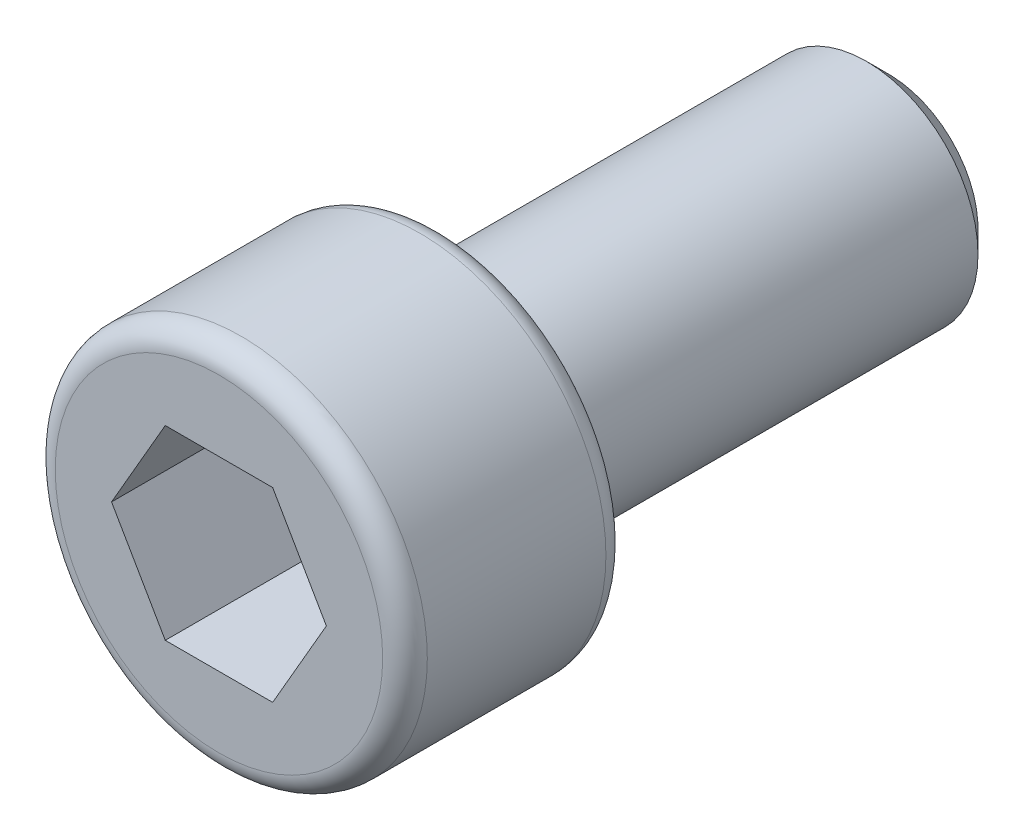
from build123d import *

# Parameters (mm, degrees)
SKETCH_1_R          = 2.5
EXTRUDE_1_DEPTH     = 3
SKETCH_2_R          = 1.5
EXTRUDE_2_DEPTH     = 6
CUT_EXTRUDE_1_DEPTH = 2
CHAMFER_1_SIZE      = 0.3
FILLET_1_R          = 0.3


with BuildPart() as part:
    # 草图1 → 凸台-拉伸1 (new body)
    with BuildSketch(Plane.XY):
        Circle(SKETCH_1_R)
    extrude(amount=EXTRUDE_1_DEPTH)

    # 草图2 → 凸台-拉伸2 (add)
    with BuildSketch(Plane(origin=(0, 0, 0), x_dir=(-1, 0, 0), z_dir=(0, 0, -1))):
        Circle(SKETCH_2_R)
    extrude(amount=EXTRUDE_2_DEPTH)

    # 草图3 → 切除-拉伸1 (cut)
    with BuildSketch(Plane.XY.offset(3)):
        Polygon((1.443375673, 0), (0.721687836, 1.25), (-0.721687836, 1.25), (-1.443375673, 0), (-0.721687836, -1.25), (0.721687836, -1.25), align=None)
    extrude(amount=-CUT_EXTRUDE_1_DEPTH, mode=Mode.SUBTRACT)

    # 倒角1
    chamfer_1_edges = [part.edges().sort_by_distance(p)[0] for p in [
        (1.5, 0, -6),
    ]]
    chamfer(chamfer_1_edges, length=CHAMFER_1_SIZE)

    # 圆角1
    fillet_1_edges = [part.edges().sort_by_distance(p)[0] for p in [
        (-2.5, 0, 0),
        (-2.5, 0, 3),
    ]]
    fillet(fillet_1_edges, radius=FILLET_1_R)


solid = part.part
